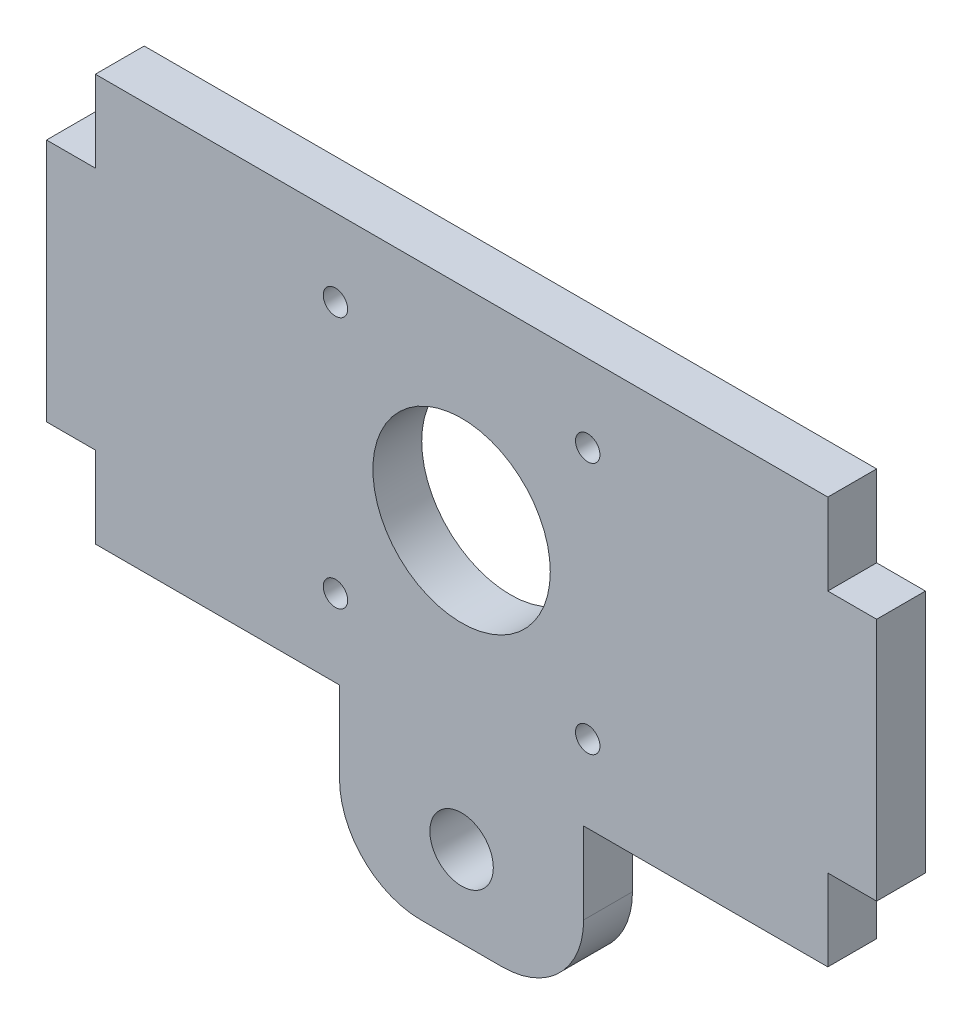
from build123d import *

# Parameters (mm, degrees)
SALIENTE_EXTRUIR1_DEPTH      = 6
CROQUIS2_W                   = 6
CROQUIS2_H                   = 30
SALIENTE_EXTRUIR2_DEPTH      = 6
SALIENTE_EXTRUIR2_DEPTH_BACK = 96
CORTAR_EXTRUIR1_REACH        = 8
CROQUIS3_R                   = 1.5
CROQUIS3_R_2                 = 10.9
CROQUIS3_R_3                 = 3.9
REDONDEO2_R                  = 10


with BuildPart() as part:
    # Croquis1 → Saliente-Extruir1 (new body)
    with BuildSketch(Plane.XY):
        Polygon((15, -25), (45, -25), (45, 25), (-45, 25), (-45, -25), (-15, -25), (-15, -45), (15, -45), align=None)
    extrude(amount=SALIENTE_EXTRUIR1_DEPTH)

    # Croquis2 → Saliente-Extruir2 (add, two sides)
    with BuildSketch(Plane.ZY.offset(45)) as saliente_extruir2_sk:
        with Locations((3, 0)):
            Rectangle(CROQUIS2_W, CROQUIS2_H)
    extrude(amount=SALIENTE_EXTRUIR2_DEPTH)
    extrude(saliente_extruir2_sk.sketch, amount=-SALIENTE_EXTRUIR2_DEPTH_BACK)

    # Croquis3 → Cortar-Extruir1 (cut, up to next)
    with BuildSketch(Plane.XY.offset(6), mode=Mode.PRIVATE) as cortar_extruir1_sk1:
        with Locations((-15.5, 15.5)):
            Circle(CROQUIS3_R)
    cortar_extruir1_tool1 = extrude(cortar_extruir1_sk1.sketch, amount=-CORTAR_EXTRUIR1_REACH, mode=Mode.PRIVATE) & part.part
    add(cortar_extruir1_tool1.solids().sort_by_distance((-15.5, 15.5, 6))[0], mode=Mode.SUBTRACT)
    # Croquis3 → Cortar-Extruir1 (cut, up to next)
    with BuildSketch(Plane.XY.offset(6), mode=Mode.PRIVATE) as cortar_extruir1_sk2:
        with Locations((15.5, 15.5)):
            Circle(CROQUIS3_R)
    cortar_extruir1_tool2 = extrude(cortar_extruir1_sk2.sketch, amount=-CORTAR_EXTRUIR1_REACH, mode=Mode.PRIVATE) & part.part
    add(cortar_extruir1_tool2.solids().sort_by_distance((15.5, 15.5, 6))[0], mode=Mode.SUBTRACT)
    # Croquis3 → Cortar-Extruir1 (cut, up to next)
    with BuildSketch(Plane.XY.offset(6), mode=Mode.PRIVATE) as cortar_extruir1_sk3:
        with Locations((15.5, -15.5)):
            Circle(CROQUIS3_R)
    cortar_extruir1_tool3 = extrude(cortar_extruir1_sk3.sketch, amount=-CORTAR_EXTRUIR1_REACH, mode=Mode.PRIVATE) & part.part
    add(cortar_extruir1_tool3.solids().sort_by_distance((15.5, -15.5, 6))[0], mode=Mode.SUBTRACT)
    # Croquis3 → Cortar-Extruir1 (cut, up to next)
    with BuildSketch(Plane.XY.offset(6), mode=Mode.PRIVATE) as cortar_extruir1_sk4:
        with Locations((-15.5, -15.5)):
            Circle(CROQUIS3_R)
    cortar_extruir1_tool4 = extrude(cortar_extruir1_sk4.sketch, amount=-CORTAR_EXTRUIR1_REACH, mode=Mode.PRIVATE) & part.part
    add(cortar_extruir1_tool4.solids().sort_by_distance((-15.5, -15.5, 6))[0], mode=Mode.SUBTRACT)
    # Croquis3 → Cortar-Extruir1 (cut, up to next)
    with BuildSketch(Plane.XY.offset(6), mode=Mode.PRIVATE) as cortar_extruir1_sk5:
        Circle(CROQUIS3_R_2)
    cortar_extruir1_tool5 = extrude(cortar_extruir1_sk5.sketch, amount=-CORTAR_EXTRUIR1_REACH, mode=Mode.PRIVATE) & part.part
    add(cortar_extruir1_tool5.solids().sort_by_distance((0, 0, 6))[0], mode=Mode.SUBTRACT)
    # Croquis3 → Cortar-Extruir1 (cut, up to next)
    with BuildSketch(Plane.XY.offset(6), mode=Mode.PRIVATE) as cortar_extruir1_sk6:
        with Locations((0, -35)):
            Circle(CROQUIS3_R_3)
    cortar_extruir1_tool6 = extrude(cortar_extruir1_sk6.sketch, amount=-CORTAR_EXTRUIR1_REACH, mode=Mode.PRIVATE) & part.part
    add(cortar_extruir1_tool6.solids().sort_by_distance((0, -35, 6))[0], mode=Mode.SUBTRACT)

    # Redondeo2
    redondeo2_edges = [part.edges().sort_by_distance(p)[0] for p in [
        (15, -45, 3),
        (-15, -45, 3),
    ]]
    fillet(redondeo2_edges, radius=REDONDEO2_R)


solid = part.part
